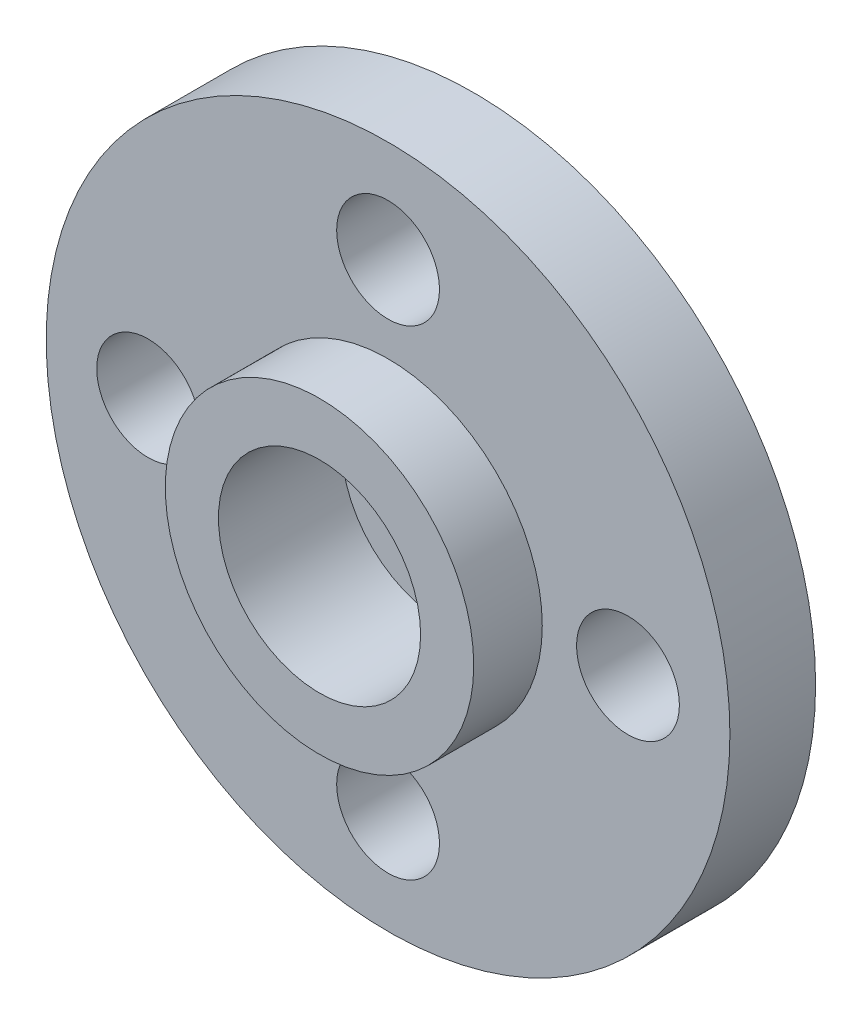
from build123d import *

# Parameters (mm, degrees)
SKETCH1_R                 = 4.5
SKETCH1_R_2               = 2.95
BOSS_EXTRUDE2_DEPTH       = 3.6
BOSS_EXTRUDE3_START       = 1.6
SKETCH1_4_R               = 9.975
SKETCH1_4_R_2             = 1.6
BOSS_EXTRUDE3_DEPTH       = 2.5
SKETCH1_6_R               = 2.95
CUT_EXTRUDE1_DEPTH        = 1.6
M3X0_5_TAPPED_HOLE1_D     = 3
M3X0_5_TAPPED_HOLE1_DEPTH = 2.5


with BuildPart() as part:
    # Sketch1 → Boss-Extrude2 (new body)
    with BuildSketch(Plane.XY):
        Circle(SKETCH1_R)
        Circle(SKETCH1_R_2, mode=Mode.SUBTRACT)
    extrude(amount=BOSS_EXTRUDE2_DEPTH)

    # Sketch1_4 → Boss-Extrude3 (add)
    with BuildSketch(Plane.XY.offset(BOSS_EXTRUDE3_START)):
        Circle(SKETCH1_4_R)
        Circle(SKETCH1_4_R_2, mode=Mode.SUBTRACT)
    extrude(amount=-BOSS_EXTRUDE3_DEPTH)

    # Sketch1_6 → Cut-Extrude1 (cut)
    with BuildSketch(Plane.XY):
        Circle(SKETCH1_6_R)
    extrude(amount=CUT_EXTRUDE1_DEPTH, mode=Mode.SUBTRACT)

    # M3x0.5 Tapped Hole1
    with Locations(Plane(origin=(0, 0, -0.9), x_dir=(-1, 0, 0), z_dir=(0, 0, -1))):
        with Locations((0, 7), (7, 0), (0, -7), (-7, 0)):
            Hole(M3X0_5_TAPPED_HOLE1_D / 2, depth=M3X0_5_TAPPED_HOLE1_DEPTH)


solid = part.part
